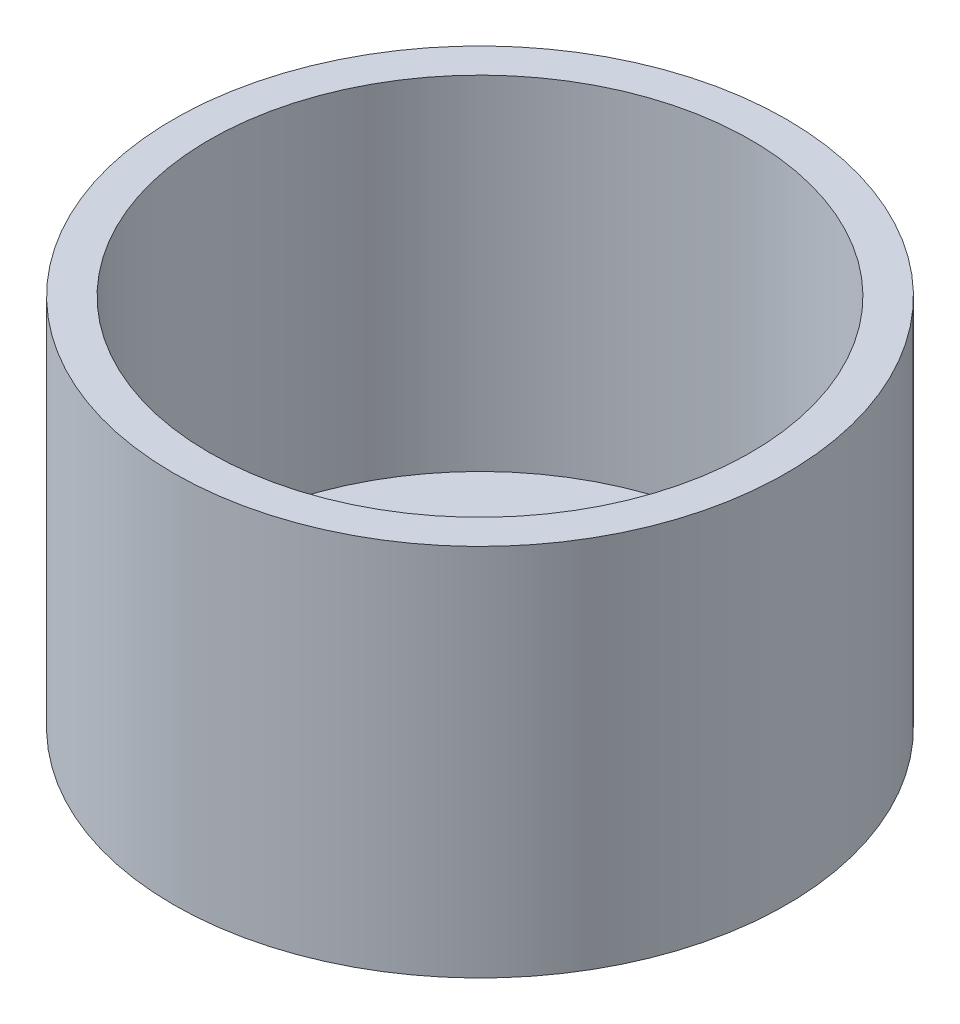
from build123d import *

# Parameters (mm, degrees)
SKETCH1_R               = 51.0286
SKETCH1_R_2             = 45.085
BOSS_EXTRUDE1_DEPTH     = 57.15
SKETCH2_R               = 51.0286
BOSS_EXTRUDE2_DEPTH     = 5.08
SKETCH3_R               = 1
CUT_EXTRUDE1_DEPTH      = 1
CUT_EXTRUDE1_DEPTH_BACK = 63.23


with BuildPart() as part:
    # Sketch1 → Boss-Extrude1 (new body)
    with BuildSketch(Plane(origin=(0, 0, 0), x_dir=(1, 0, 0), z_dir=(0, 1, 0))):
        Circle(SKETCH1_R)
        Circle(SKETCH1_R_2, mode=Mode.SUBTRACT)
    extrude(amount=BOSS_EXTRUDE1_DEPTH)

    # Sketch2 → Boss-Extrude2 (add)
    with BuildSketch(Plane.XZ):
        Circle(SKETCH2_R)
    extrude(amount=BOSS_EXTRUDE2_DEPTH)

    # Sketch3 → Cut-Extrude1 (cut, two sides)
    with BuildSketch(Plane(origin=(0, -5.08, 0), x_dir=(-1, 0, 0), z_dir=(0, -1, 0))) as cut_extrude1_sk:
        with Locations((14.049999967, -7.349999968)):
            Circle(SKETCH3_R)
        with Locations((14.049999967, -12.349999968)):
            Circle(SKETCH3_R)
        with Locations((19.049999967, -12.349999968)):
            Circle(SKETCH3_R)
        with Locations((19.049999967, -7.349999968)):
            Circle(SKETCH3_R)
        with Locations((19.049999967, 7.350000032)):
            Circle(SKETCH3_R)
        with Locations((19.049999967, 12.350000032)):
            Circle(SKETCH3_R)
        with Locations((14.049999967, 12.350000032)):
            Circle(SKETCH3_R)
        with Locations((-14.050000033, 12.350000032)):
            Circle(SKETCH3_R)
        with Locations((-14.050000033, 7.350000032)):
            Circle(SKETCH3_R)
        with Locations((-19.050000033, 12.350000032)):
            Circle(SKETCH3_R)
        with Locations((-19.050000033, 7.350000032)):
            Circle(SKETCH3_R)
        with Locations((-19.050000033, -7.349999968)):
            Circle(SKETCH3_R)
        with Locations((-14.050000033, -7.349999968)):
            Circle(SKETCH3_R)
        with Locations((-14.050000033, -12.349999968)):
            Circle(SKETCH3_R)
        with Locations((-19.050000033, -12.349999968)):
            Circle(SKETCH3_R)
        with Locations((14.049999967, 7.350000032)):
            Circle(SKETCH3_R)
    extrude(amount=CUT_EXTRUDE1_DEPTH, mode=Mode.SUBTRACT)
    extrude(cut_extrude1_sk.sketch, amount=-CUT_EXTRUDE1_DEPTH_BACK, mode=Mode.SUBTRACT)


solid = part.part
